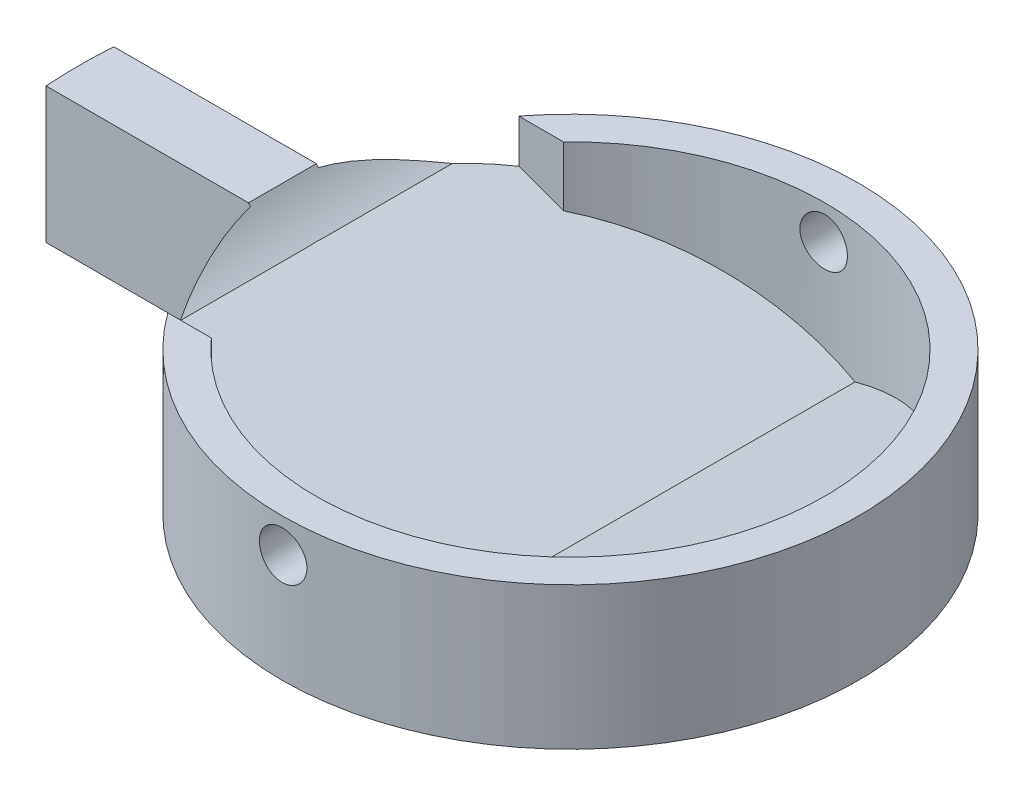
from build123d import *

# Parameters (mm, degrees)
SKETCH1_R               = 10.795
BOSS_EXTRUDE1_DEPTH     = 2.54
SKETCH2_R               = 10.795
SKETCH2_R_2             = 9.525
BOSS_EXTRUDE2_DEPTH     = 10.16
BOSS_EXTRUDE3_DEPTH     = 9.525
SKETCH4_R               = 13.470384182
SKETCH4_R_2             = 10.795
CUT_EXTRUDE1_DEPTH      = 12.7
BOSS_EXTRUDE4_DEPTH     = 5.08
SKETCH8_R               = 0.889
CUT_EXTRUDE7_DEPTH      = 11.795
CUT_EXTRUDE7_DEPTH_BACK = 11.795
CUT_EXTRUDE8_DEPTH      = 12.954
BOSS_EXTRUDE5_DEPTH     = 10.668
CUT_EXTRUDE9_DEPTH      = 12.7
SKETCH12_R              = 10.795
CUT_EXTRUDE10_DEPTH     = 7.366


with BuildPart() as part:
    # Sketch1 → Boss-Extrude1 (new body)
    with BuildSketch(Plane(origin=(0, 0, 0), x_dir=(1, 0, 0), z_dir=(0, 1, 0))):
        Circle(SKETCH1_R)
    extrude(amount=BOSS_EXTRUDE1_DEPTH)

    # Sketch2 → Boss-Extrude2 (add)
    with BuildSketch(Plane(origin=(0, 2.54, 0), x_dir=(1, 0, 0), z_dir=(0, 1, 0))):
        Circle(SKETCH2_R)
        Circle(SKETCH2_R_2, mode=Mode.SUBTRACT)
    extrude(amount=BOSS_EXTRUDE2_DEPTH)

    # Sketch3 → Boss-Extrude3 (add, symmetric)
    with BuildSketch(Plane.XY):
        Polygon((-9.525, 11.43), (-9.525, 2.54), (9.525, 2.54), (9.525, 4.513407944), align=None)
    extrude(amount=BOSS_EXTRUDE3_DEPTH, both=True)

    # Sketch4 → Cut-Extrude1 (cut)
    with BuildSketch(Plane(origin=(0, 12.7, 0), x_dir=(1, 0, 0), z_dir=(0, 1, 0))):
        Circle(SKETCH4_R)
        Circle(SKETCH4_R_2, mode=Mode.SUBTRACT)
    extrude(amount=-CUT_EXTRUDE1_DEPTH, mode=Mode.SUBTRACT)

    # Sketch5 → Boss-Extrude4 (add)
    with BuildSketch(Plane(origin=(0, 12.7, 0), x_dir=(1, 0, 0), z_dir=(0, 1, 0))):
        with BuildLine():
            Line((-9.525, 1.27), (-18.3711547, 1.27))
            ThreePointArc((-18.3711547, 1.27), (-18.415, 0), (-18.3711547, -1.27))
            Line((-18.3711547, -1.27), (-9.525, -1.27))
            Line((-9.525, -1.27), (-9.525, 1.27))
        make_face()
    extrude(amount=-BOSS_EXTRUDE4_DEPTH)

    # Sketch8 → Cut-Extrude7 (cut, two sides)
    with BuildSketch(Plane.XY) as cut_extrude7_sk:
        with Locations((0, 11.43)):
            Circle(SKETCH8_R)
    extrude(amount=CUT_EXTRUDE7_DEPTH, mode=Mode.SUBTRACT)
    extrude(cut_extrude7_sk.sketch, amount=-CUT_EXTRUDE7_DEPTH_BACK, mode=Mode.SUBTRACT)

    # Sketch9 → Cut-Extrude8 (cut)
    with BuildSketch(Plane(origin=(0, 0, -6.604), x_dir=(-1, 0, 0), z_dir=(0, 0, -1))):
        with BuildLine():
            Line((11.634433815, 14.99553097), (5.6711547, 16.064639109))
            Line((5.6711547, 16.064639109), (5.6711547, 10.030762426))
            Line((5.6711547, 10.030762426), (7.137641273, 10.563208063))
            Line((7.137641273, 10.563208063), (9.51829444, 11.427565374))
            ThreePointArc((9.51829444, 11.427565374), (10.966421538, 12.98020742), (11.634433815, 14.99553097))
        make_face()
    extrude(amount=-CUT_EXTRUDE8_DEPTH, mode=Mode.SUBTRACT)

    # Sketch10 → Boss-Extrude5 (add, symmetric)
    with BuildSketch(Plane.XY):
        Polygon((9.524784171, 4.513486306), (-7.099515829, 4.51432564), (9.524784171, 10.54936564), align=None)
    extrude(amount=BOSS_EXTRUDE5_DEPTH, both=True)

    # Sketch11 → Cut-Extrude9 (cut)
    with BuildSketch(Plane(origin=(0, 12.7, 0), x_dir=(1, 0, 0), z_dir=(0, 1, 0))):
        with BuildLine():
            Line((-10.452691986, -2.696897336), (-9.948623227, -10.980573455))
            ThreePointArc((-9.948623227, -10.980573455), (14.816931941, 0.081396449), (-10.068662158, 10.870608993))
            Line((-10.068662158, 10.870608993), (-10.452691986, 2.696897336))
            ThreePointArc((-10.452691986, 2.696897336), (-9.694847114, 4.747837869), (-8.539274501, 6.604))
            ThreePointArc((-8.539274501, 6.604), (10.793832515, -0.15875966), (-8.729806699, -6.35))
            ThreePointArc((-8.729806699, -6.35), (-9.763624006, -4.604744431), (-10.452691986, -2.696897336))
        make_face()
    extrude(amount=-CUT_EXTRUDE9_DEPTH, mode=Mode.SUBTRACT)

    # Sketch12 → Cut-Extrude10 (cut)
    with BuildSketch(Plane.XZ):
        Circle(SKETCH12_R)
    extrude(amount=-CUT_EXTRUDE10_DEPTH, mode=Mode.SUBTRACT)


solid = part.part
